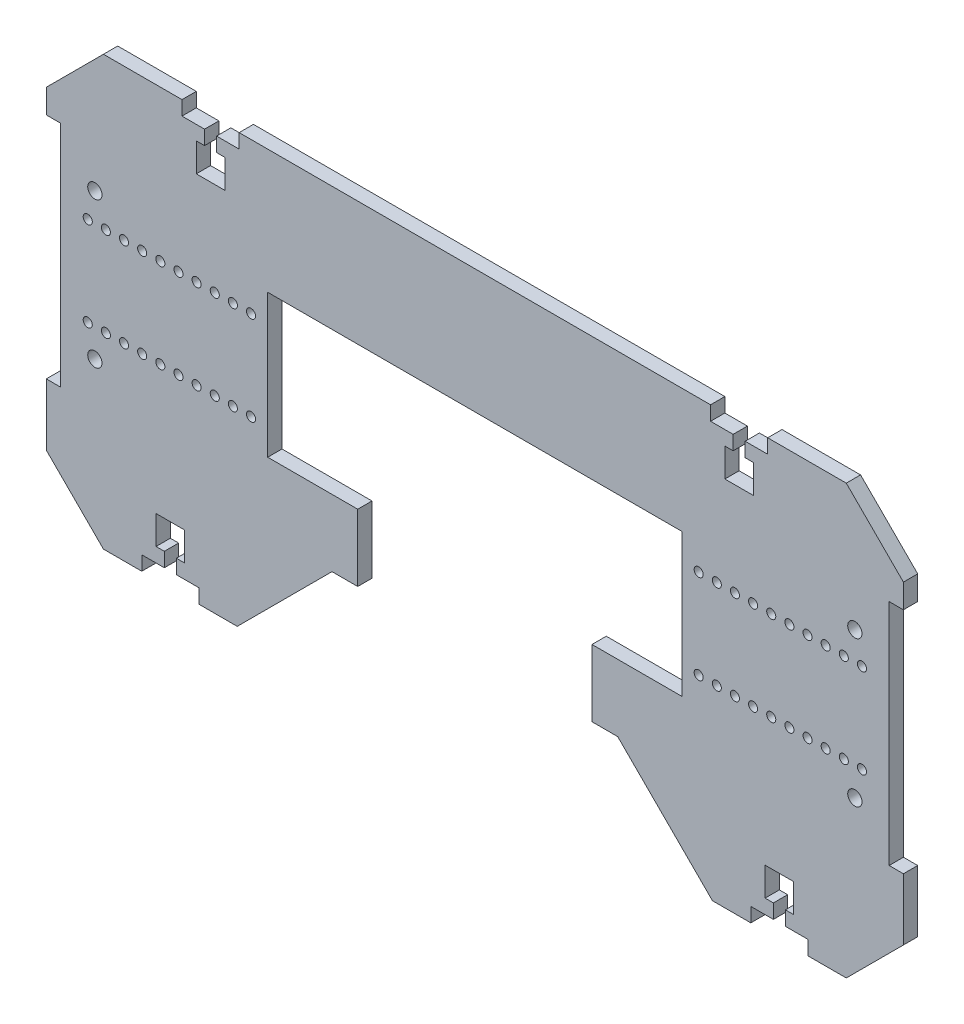
from build123d import *

# Parameters (mm, degrees)
SKETCH1_W           = 40
SKETCH1_H           = 50
BOSS_EXTRUDE1_DEPTH = 5
CUT_EXTRUDE1_DEPTH  = 169.198858526
FILLET1_R           = 3
SKETCH3_R           = 1.5875
CUT_EXTRUDE2_DEPTH  = 169.198858526
CUT_EXTRUDE3_DEPTH  = 169.198858526
CUT_EXTRUDE5_DEPTH  = 5
SKETCH7_R           = 2.5
CUT_EXTRUDE6_DEPTH  = 5
SKETCH8_W           = 65
SKETCH8_H           = 22.934618833
CUT_EXTRUDE7_DEPTH  = 5


with BuildPart() as part:
    # Sketch1 → Boss-Extrude1 (new body)
    with BuildSketch(Plane.XY):
        with BuildLine():
            Line((149.732146976, -33.800912799), (144.732146976, -33.800912799))
            Line((144.732146976, -33.800912799), (144.732146976, 46.199087201))
            Line((144.732146976, 46.199087201), (149.732146976, 46.199087201))
            Line((149.732146976, 46.199087201), (149.732146976, 54.598220465))
            Line((149.732146976, 54.598220465), (129.732146976, 74.598220465))
            Line((129.732146976, 74.598220465), (-130.267853024, 74.598220465))
            Line((-130.267853024, 74.598220465), (-150.267853024, 54.598220465))
            Line((-150.267853024, 54.598220465), (-150.267853024, 46.199087201))
            Line((-150.267853024, 46.199087201), (-145.267853024, 46.199087201))
            Line((-145.267853024, 46.199087201), (-145.267853024, -33.800912799))
            Line((-145.267853024, -33.800912799), (-150.267853024, -33.800912799))
            Line((-150.267853024, -33.800912799), (-150.267853024, -55.401779535))
            Line((-150.267853024, -55.401779535), (-130.267853024, -75.401779535))
            Line((-130.267853024, -75.401779535), (-83.434100927, -75.401779535))
            Line((-83.434100927, -75.401779535), (-50.267853024, -42.235531632))
            Line((-50.267853024, -42.235531632), (-28.267853024, -42.235531632))
            ThreePointArc((-28.267853024, -42.235531632), (-26.14653268, -41.356851975), (-25.267853024, -39.235531632))
            Line((-25.267853024, -39.235531632), (-25.267853024, 1.264468368))
            ThreePointArc((-25.267853024, 1.264468368), (-24.389173367, 3.385788712), (-22.267853024, 4.264468368))
            Line((-22.267853024, 4.264468368), (21.732146976, 4.264468368))
            ThreePointArc((21.732146976, 4.264468368), (23.85346732, 3.385788712), (24.732146976, 1.264468368))
            Line((24.732146976, 1.264468368), (24.732146976, -39.235531632))
            ThreePointArc((24.732146976, -39.235531632), (25.610826633, -41.356851975), (27.732146976, -42.235531632))
            Line((27.732146976, -42.235531632), (49.732146976, -42.235531632))
            Line((49.732146976, -42.235531632), (82.89839488, -75.401779535))
            Line((82.89839488, -75.401779535), (129.732146976, -75.401779535))
            Line((129.732146976, -75.401779535), (149.732146976, -55.401779535))
            Line((149.732146976, -55.401779535), (149.732146976, -33.800912799))
        make_face()
        with Locations((-52.767853024, 6.199087201)):
            Rectangle(SKETCH1_W, SKETCH1_H, mode=Mode.SUBTRACT)
        with Locations((52.232146976, 6.199087201)):
            Rectangle(SKETCH1_W, SKETCH1_H, mode=Mode.SUBTRACT)
    extrude(amount=BOSS_EXTRUDE1_DEPTH)

    # Sketch2 → Cut-Extrude1 (cut, through all)
    with BuildSketch(Plane.XY.offset(5)):
        with BuildLine():
            ThreePointArc((21.732146976, 4.264468368), (23.85346732, 3.385788712), (24.732146976, 1.264468368))
            Line((24.732146976, 1.264468368), (24.732146976, -39.235531632))
            ThreePointArc((24.732146976, -39.235531632), (25.610826633, -41.356851975), (27.732146976, -42.235531632))
            Line((27.732146976, -42.235531632), (28.732146976, -42.235531632))
            Line((28.732146976, -42.235531632), (28.732146976, -38.362548286))
            Line((28.732146976, -38.362548286), (28.732146976, 1.264468368))
            ThreePointArc((28.732146976, 1.264468368), (26.681894445, 6.214215837), (21.732146976, 8.264468368))
            Line((21.732146976, 8.264468368), (-22.267853024, 8.264468368))
            ThreePointArc((-22.267853024, 8.264468368), (-27.217600492, 6.214215837), (-29.267853024, 1.264468368))
            Line((-29.267853024, 1.264468368), (-29.267853024, -38.362548286))
            Line((-29.267853024, -38.362548286), (-29.267853024, -42.235531632))
            Line((-29.267853024, -42.235531632), (-28.267853024, -42.235531632))
            ThreePointArc((-28.267853024, -42.235531632), (-26.14653268, -41.356851975), (-25.267853024, -39.235531632))
            Line((-25.267853024, -39.235531632), (-25.267853024, 1.264468368))
            ThreePointArc((-25.267853024, 1.264468368), (-24.389173367, 3.385788712), (-22.267853024, 4.264468368))
            Line((-22.267853024, 4.264468368), (21.732146976, 4.264468368))
        make_face()
    extrude(amount=-CUT_EXTRUDE1_DEPTH, mode=Mode.SUBTRACT)

    # Fillet1
    fillet1_edges = [part.edges().sort_by_distance(p)[0] for p in [
        (28.732146976, -42.235531632, 2.5),
        (-29.267853024, -42.235531632, 2.5),
    ]]
    fillet(fillet1_edges, radius=FILLET1_R)

    # Sketch3 → Cut-Extrude2 (cut, through all)
    with BuildSketch(Plane.XY.offset(5)):
        with Locations((-78.605353024, -9.421912799)):
            Circle(SKETCH3_R)
        with Locations((-78.605353024, 21.820087201)):
            Circle(SKETCH3_R)
        with Locations((-84.955353024, -9.421912799)):
            Circle(SKETCH3_R)
        with Locations((-84.955353024, 21.820087201)):
            Circle(SKETCH3_R)
        with Locations((-91.305353024, -9.421912799)):
            Circle(SKETCH3_R)
        with Locations((-91.305353024, 21.820087201)):
            Circle(SKETCH3_R)
        with Locations((-97.655353024, -9.421912799)):
            Circle(SKETCH3_R)
        with Locations((-97.655353024, 21.820087201)):
            Circle(SKETCH3_R)
        with Locations((-104.005353024, -9.421912799)):
            Circle(SKETCH3_R)
        with Locations((-104.005353024, 21.820087201)):
            Circle(SKETCH3_R)
        with Locations((-110.355353024, -9.421912799)):
            Circle(SKETCH3_R)
        with Locations((-110.355353024, 21.820087201)):
            Circle(SKETCH3_R)
        with Locations((-116.705353024, -9.421912799)):
            Circle(SKETCH3_R)
        with Locations((-116.705353024, 21.820087201)):
            Circle(SKETCH3_R)
        with Locations((-123.055353024, -9.421912799)):
            Circle(SKETCH3_R)
        with Locations((-123.055353024, 21.820087201)):
            Circle(SKETCH3_R)
        with Locations((-129.405353024, -9.421912799)):
            Circle(SKETCH3_R)
        with Locations((-129.405353024, 21.820087201)):
            Circle(SKETCH3_R)
        with Locations((-135.755353024, -9.421912799)):
            Circle(SKETCH3_R)
        with Locations((-135.755353024, 21.820087201)):
            Circle(SKETCH3_R)
        with Locations(Location((135.219646976, 21.820087201, 0), (0, 0, 180))):
            Circle(SKETCH3_R)
        with Locations(Location((135.219646976, -9.421912799, 0), (0, 0, 180))):
            Circle(SKETCH3_R)
        with Locations(Location((128.869646976, 21.820087201, 0), (0, 0, 180))):
            Circle(SKETCH3_R)
        with Locations(Location((128.869646976, -9.421912799, 0), (0, 0, 180))):
            Circle(SKETCH3_R)
        with Locations(Location((122.519646976, 21.820087201, 0), (0, 0, 180))):
            Circle(SKETCH3_R)
        with Locations(Location((122.519646976, -9.421912799, 0), (0, 0, 180))):
            Circle(SKETCH3_R)
        with Locations(Location((116.169646976, 21.820087201, 0), (0, 0, 180))):
            Circle(SKETCH3_R)
        with Locations(Location((116.169646976, -9.421912799, 0), (0, 0, 180))):
            Circle(SKETCH3_R)
        with Locations(Location((109.819646976, 21.820087201, 0), (0, 0, 180))):
            Circle(SKETCH3_R)
        with Locations(Location((109.819646976, -9.421912799, 0), (0, 0, 180))):
            Circle(SKETCH3_R)
        with Locations(Location((103.469646976, 21.820087201, 0), (0, 0, 180))):
            Circle(SKETCH3_R)
        with Locations(Location((103.469646976, -9.421912799, 0), (0, 0, 180))):
            Circle(SKETCH3_R)
        with Locations(Location((97.119646976, 21.820087201, 0), (0, 0, 180))):
            Circle(SKETCH3_R)
        with Locations(Location((97.119646976, -9.421912799, 0), (0, 0, 180))):
            Circle(SKETCH3_R)
        with Locations(Location((90.769646976, 21.820087201, 0), (0, 0, 180))):
            Circle(SKETCH3_R)
        with Locations(Location((90.769646976, -9.421912799, 0), (0, 0, 180))):
            Circle(SKETCH3_R)
        with Locations(Location((84.419646976, 21.820087201, 0), (0, 0, 180))):
            Circle(SKETCH3_R)
        with Locations(Location((84.419646976, -9.421912799, 0), (0, 0, 180))):
            Circle(SKETCH3_R)
        with Locations(Location((78.069646976, 21.820087201, 0), (0, 0, 180))):
            Circle(SKETCH3_R)
        with Locations(Location((78.069646976, -9.421912799, 0), (0, 0, 180))):
            Circle(SKETCH3_R)
    extrude(amount=-CUT_EXTRUDE2_DEPTH, mode=Mode.SUBTRACT)

    # Sketch4 → Cut-Extrude3 (cut, through all)
    with BuildSketch(Plane.XY.offset(5)):
        with BuildLine():
            Line((-41.267853024, -42.235531632), (-41.267853024, -18.800912799))
            Line((-41.267853024, -18.800912799), (-32.767853024, -18.800912799))
            Line((-32.767853024, -18.800912799), (-32.767853024, 8.264468368))
            Line((-32.767853024, 8.264468368), (-22.267853024, 8.264468368))
            ThreePointArc((-22.267853024, 8.264468368), (-27.217600492, 6.214215837), (-29.267853024, 1.264468368))
            Line((-29.267853024, 1.264468368), (-29.267853024, -39.235531632))
            ThreePointArc((-29.267853024, -39.235531632), (-30.14653268, -41.356851975), (-32.267853024, -42.235531632))
            Line((-32.267853024, -42.235531632), (-41.267853024, -42.235531632))
        make_face()
        with BuildLine():
            Line((21.732146976, 8.264468368), (32.232146976, 8.264468368))
            Line((32.232146976, 8.264468368), (32.232146976, -18.800912799))
            Line((32.232146976, -18.800912799), (40.732146976, -18.800912799))
            Line((40.732146976, -18.800912799), (40.732146976, -42.235531632))
            Line((40.732146976, -42.235531632), (31.732146976, -42.235531632))
            ThreePointArc((31.732146976, -42.235531632), (29.610826633, -41.356851975), (28.732146976, -39.235531632))
            Line((28.732146976, -39.235531632), (28.732146976, 1.264468368))
            ThreePointArc((28.732146976, 1.264468368), (26.681894445, 6.214215837), (21.732146976, 8.264468368))
        make_face()
    extrude(amount=-CUT_EXTRUDE3_DEPTH, mode=Mode.SUBTRACT)

    # Sketch6 → Cut-Extrude5 (cut)
    with BuildSketch(Plane.XY.offset(5)):
        Polygon((-102.767853024, 74.598220465), (-102.767853024, 69.598220465), (-94.867853024, 69.598220465), (-94.867853024, 64.598220465), (-97.767853024, 64.598220465), (-97.767853024, 54.598220465), (-87.767853024, 54.598220465), (-87.767853024, 64.598220465), (-90.667853024, 64.598220465), (-90.667853024, 69.598220465), (-82.767853024, 69.598220465), (-82.767853024, 74.598220465), align=None)
        Polygon((-116.850976975, -75.401779535), (-116.850976975, -70.401779535), (-108.950976975, -70.401779535), (-108.950976975, -65.401779535), (-111.850976975, -65.401779535), (-111.850976975, -55.401779535), (-101.850976975, -55.401779535), (-101.850976975, -65.401779535), (-104.750976975, -65.401779535), (-104.750976975, -70.401779535), (-96.850976975, -70.401779535), (-96.850976975, -75.401779535), align=None)
        Polygon((104.215270928, -70.401779535), (96.315270928, -70.401779535), (96.315270928, -75.401779535), (116.315270928, -75.401779535), (116.315270928, -70.401779535), (108.415270928, -70.401779535), (108.415270928, -65.401779535), (111.315270928, -65.401779535), (111.315270928, -55.401779535), (101.315270928, -55.401779535), (101.315270928, -65.401779535), (104.215270928, -65.401779535), align=None)
        Polygon((90.132146976, 69.598220465), (82.232146976, 69.598220465), (82.232146976, 74.598220465), (102.232146976, 74.598220465), (102.232146976, 69.598220465), (94.332146976, 69.598220465), (94.332146976, 64.598220465), (97.232146976, 64.598220465), (97.232146976, 54.598220465), (87.232146976, 54.598220465), (87.232146976, 64.598220465), (90.132146976, 64.598220465), align=None)
    extrude(amount=-CUT_EXTRUDE5_DEPTH, mode=Mode.SUBTRACT)

    # Sketch7 → Cut-Extrude6 (cut)
    with BuildSketch(Plane.XY.offset(5)):
        with Locations((-133.267853024, -19.300912799)):
            Circle(SKETCH7_R)
        with Locations((-133.267853024, 31.699087201)):
            Circle(SKETCH7_R)
        with Locations((132.732146976, -19.300912799)):
            Circle(SKETCH7_R)
        with Locations((132.732146976, 31.699087201)):
            Circle(SKETCH7_R)
    extrude(amount=-CUT_EXTRUDE6_DEPTH, mode=Mode.SUBTRACT)

    # Sketch8 → Cut-Extrude7 (cut)
    with BuildSketch(Plane.XY.offset(5)):
        with Locations((-0.267853024, 19.731777785)):
            Rectangle(SKETCH8_W, SKETCH8_H)
    extrude(amount=-CUT_EXTRUDE7_DEPTH, mode=Mode.SUBTRACT)


solid = part.part
